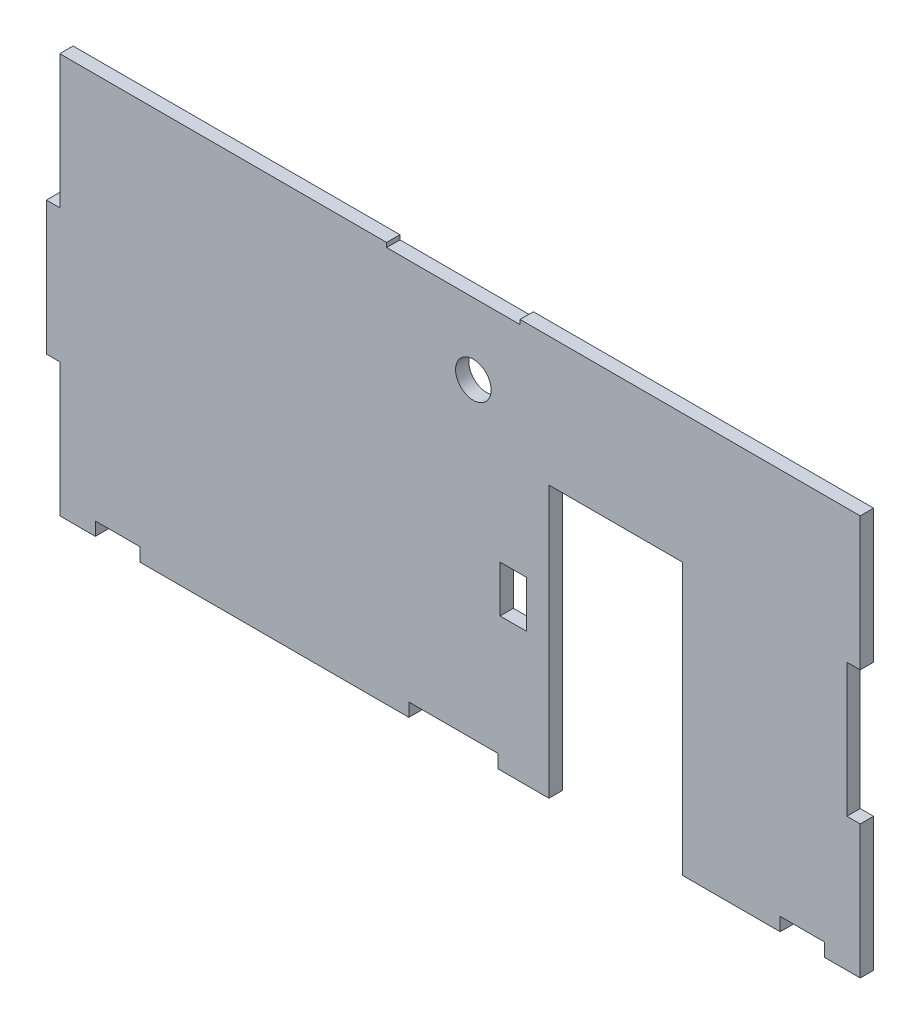
from build123d import *

# Parameters (mm, degrees)
MODEL_R             = 4
MODEL_W             = 6
MODEL_H             = 10.5
BOSS_EXTRUDE1_DEPTH = 3


with BuildPart() as part:
    # Model → Boss-Extrude1 (new body)
    with BuildSketch(Plane.XY):
        Polygon((-215.742718731, 39.275539879), (-157.242718731, 39.275539879), (-157.242718731, 42.275539879), (-137.242718731, 42.275539879), (-137.242718731, 39.275539879), (-125.742718731, 39.275539879), (-125.742718731, 100.275539879), (-95.742718731, 100.275539879), (-95.742718731, 39.275539879), (-73.742718731, 39.275539879), (-73.742718731, 42.275539879), (-63.742718731, 42.275539879), (-63.742718731, 39.275539879), (-55.742718731, 39.275539879), (-55.742718731, 69.275539879), (-58.742718731, 69.275539879), (-58.742718731, 99.275539879), (-55.742718731, 99.275539879), (-55.742718731, 129.275539879), (-132.242718731, 129.275539879), (-132.242718731, 128.275539879), (-162.242718731, 128.275539879), (-162.242718731, 129.275539879), (-235.742718731, 129.275539879), (-235.742718731, 99.275539879), (-238.742718731, 99.275539879), (-238.742718731, 69.275539879), (-235.742718731, 69.275539879), (-235.742718731, 39.275539879), (-227.742718731, 39.275539879), (-227.742718731, 42.275539879), (-217.742718731, 42.275539879), (-217.742718731, 39.275539879), align=None)
        with Locations((-142.742718731, 112.275539879)):
            Circle(MODEL_R, mode=Mode.SUBTRACT)
        with Locations((-133.742718731, 74.525539879)):
            Rectangle(MODEL_W, MODEL_H, mode=Mode.SUBTRACT)
    extrude(amount=BOSS_EXTRUDE1_DEPTH)


solid = part.part
